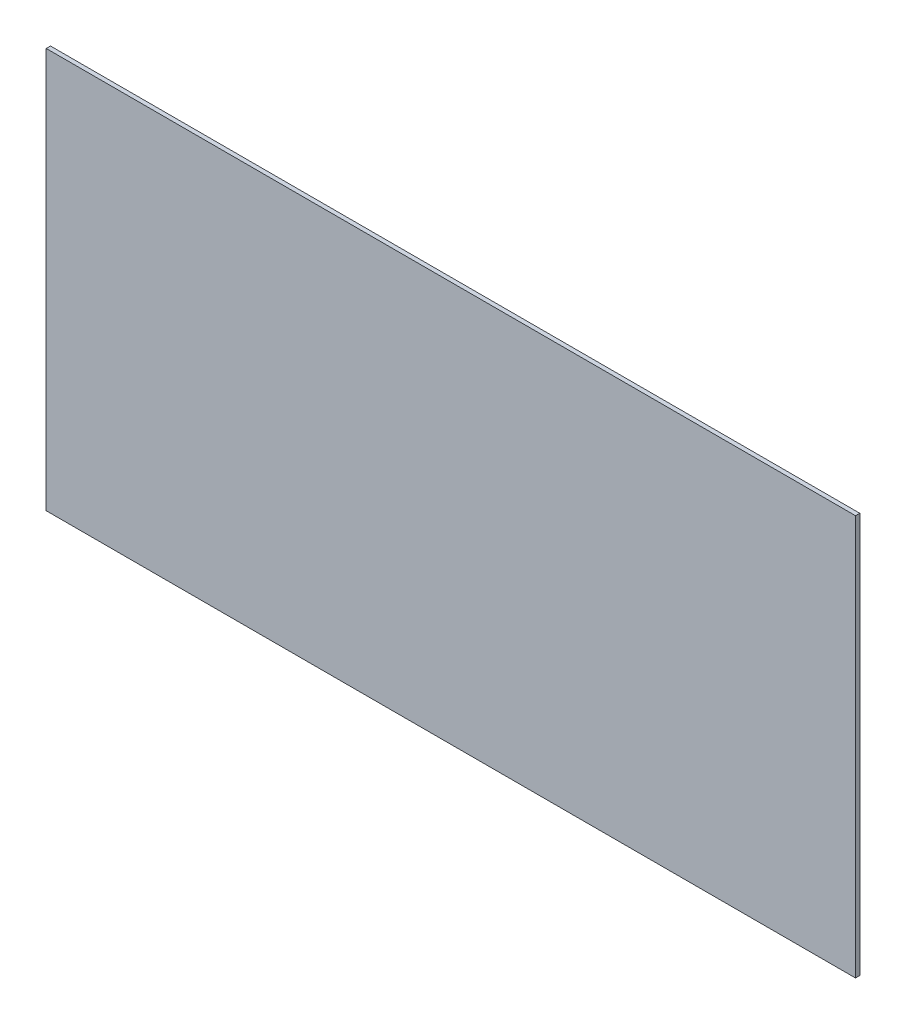
from build123d import *

# Parameters (mm, degrees)
SKETCH1_W           = 603.25
SKETCH1_H           = 298.45
BOSS_EXTRUDE1_DEPTH = 3.175


with BuildPart() as part:
    # Sketch1 → Boss-Extrude1 (new body)
    with BuildSketch(Plane.XY):
        with Locations((301.625, 149.225)):
            Rectangle(SKETCH1_W, SKETCH1_H)
    extrude(amount=BOSS_EXTRUDE1_DEPTH)


solid = part.part
